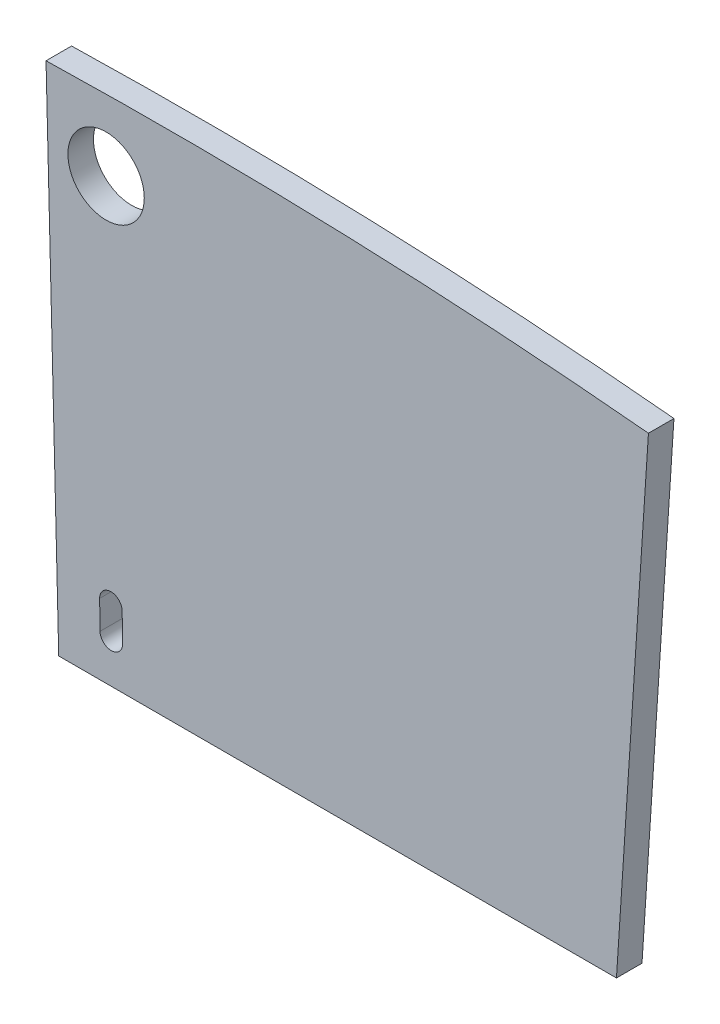
from build123d import *

# Parameters (mm, degrees)
EXTRUDE1_DEPTH     = 0.9
EXTRUDE2_DEPTH     = 0.9
SKETCH3_R          = 1.346200001
CUT_EXTRUDE2_DEPTH = 1.9
EXTRUDE3_DEPTH     = 1.9
CUT_EXTRUDE3_DEPTH = 1.9
FILLET1_R          = 0.5
CUT_EXTRUDE4_DEPTH = 1.9


with BuildPart() as part:
    # Sketch1 → Extrude1 (new body)
    with BuildSketch(Plane.XY):
        Polygon((-16.337044405, 167.45476352), (16.337044405, 167.45476352), (16.002062475, 162.343926895), (-16.002062475, 162.343926895), align=None)
    extrude(amount=EXTRUDE1_DEPTH)

    # Sketch2 → Extrude2 (add)
    with BuildSketch(Plane(origin=(0, 0, 0), x_dir=(-1, 0, 0), z_dir=(0, 0, -1))):
        with BuildLine():
            Line((16.84417657, 175.192105175), (15.717346464, 158))
            Line((15.717346464, 158), (-15.717346464, 158))
            Line((-15.717346464, 158), (-16.84417657, 175.192105175))
            ThreePointArc((-16.84417657, 175.192105175), (0, 176), (16.84417657, 175.192105175))
        make_face()
    extrude(amount=-EXTRUDE2_DEPTH)

    # Sketch3 → Cut-Extrude2 (cut, through all)
    with BuildSketch(Plane.XY):
        with Locations((-2.271044833, 173.485135834)):
            Circle(SKETCH3_R)
        with BuildLine():
            Line((-1.704039652, 160.491487345), (-1.690948935, 159.491487345))
            ThreePointArc((-1.690948935, 159.491487345), (-2.082595001, 159.089451413), (-2.484630933, 159.481097479))
            Line((-2.484630933, 159.481097479), (-2.49772165, 160.481097479))
            ThreePointArc((-2.49772165, 160.481097479), (-2.106075584, 160.883133411), (-1.704039652, 160.491487345))
        make_face()
    extrude(amount=CUT_EXTRUDE2_DEPTH, mode=Mode.SUBTRACT)

    # Sketch4 → Extrude3 (cut, through all)
    with BuildSketch(Plane.XY.offset(0.9)):
        with BuildLine():
            Line((-12, 175.590432541), (-12, 171))
            ThreePointArc((-12, 171), (-12.292893219, 170.292893219), (-13, 170))
            Line((-13, 170), (-16.503868017, 170))
            Line((-16.503868017, 170), (-16.84417657, 175.192105175))
            ThreePointArc((-16.84417657, 175.192105175), (-14.423463408, 175.407992131), (-12, 175.590432541))
        make_face()
    extrude(amount=-EXTRUDE3_DEPTH, mode=Mode.SUBTRACT)

    # Sketch5 → Cut-Extrude3 (cut, through all)
    with BuildSketch(Plane.XY.offset(0.9)):
        with BuildLine():
            Line((-5.934879033, 175.899906796), (-5.934879033, 173.754533822))
            Line((-5.934879033, 173.754533822), (-13.425811407, 173.754533822))
            Line((-13.425811407, 173.754533822), (-13.425811407, 175.487172147))
            ThreePointArc((-13.425811407, 175.487172147), (-9.682544658, 175.733458194), (-5.934879033, 175.899906796))
        make_face()
    extrude(amount=-CUT_EXTRUDE3_DEPTH, mode=Mode.SUBTRACT)

    # Fillet1
    fillet1_edges = [part.edges().sort_by_distance(p)[0] for p in [
        (-5.934879033, 173.754533822, 0.45),
    ]]
    fillet(fillet1_edges, radius=FILLET1_R)

    # Sketch6 → Cut-Extrude4 (cut, through all)
    with BuildSketch(Plane(origin=(0, 0, 0), x_dir=(-1, 0, 0), z_dir=(0, 0, -1))):
        with BuildLine():
            Line((3.939992499, 158), (4.387488465, 175.945303845))
            ThreePointArc((4.387488465, 175.945303845), (5.161233662, 175.924306641), (5.934879033, 175.899906796))
            Line((5.934879033, 175.899906796), (5.934879033, 174.254533822))
            ThreePointArc((5.934879033, 174.254533822), (6.081325642, 173.900980431), (6.434879033, 173.754533822))
            Line((6.434879033, 173.754533822), (12, 173.754533822))
            Line((12, 173.754533822), (12, 171))
            ThreePointArc((12, 171), (12.292893219, 170.292893219), (13, 170))
            Line((13, 170), (16.503868017, 170))
            Line((16.503868017, 170), (15.717346464, 158))
            Line((15.717346464, 158), (3.939992499, 158))
        make_face()
    extrude(amount=-CUT_EXTRUDE4_DEPTH, mode=Mode.SUBTRACT)


solid = part.part
